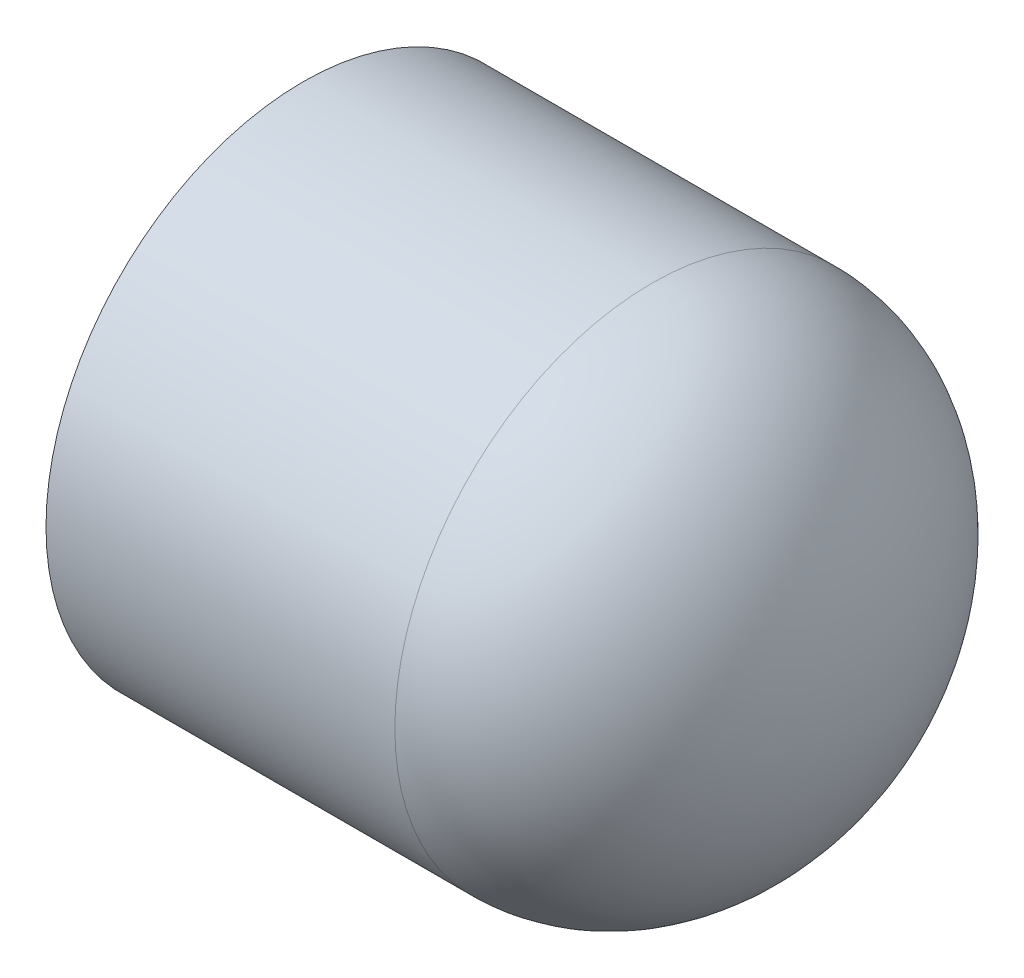
from build123d import *


with BuildPart() as part:
    # Sketch1 → Revolve1 (revolve)
    with BuildSketch(Plane.XY):
        with BuildLine():
            Line((18.0594, 0), (22.0091, 0))
            add(Edge.make_bspline(
                [(5.9309, -20.5867), (22.0091, -20.5867), (22.0091, 0)],
                knots=[3.141592654, 3.141592654, 3.141592654, 4.71238898, 4.71238898, 4.71238898], degree=2, weights=[1, 0.707106781, 1]))
            Line((5.9309, -20.5867), (-22.0091, -20.5867))
            Line((-22.0091, -20.5867), (-22.0091, -16.8275))
            Line((-22.0091, -16.8275), (5.9309, -16.637))
            add(Edge.make_bspline(
                [(5.9309, -16.637), (18.0594, -16.637), (18.0594, 0)],
                knots=[0, 0, 0, 1.570796327, 1.570796327, 1.570796327], degree=2, weights=[1, 0.707106781, 1]))
        make_face()
    revolve(axis=Axis((-22.0091, 0, 0), (1, 0, 0)))


solid = part.part
